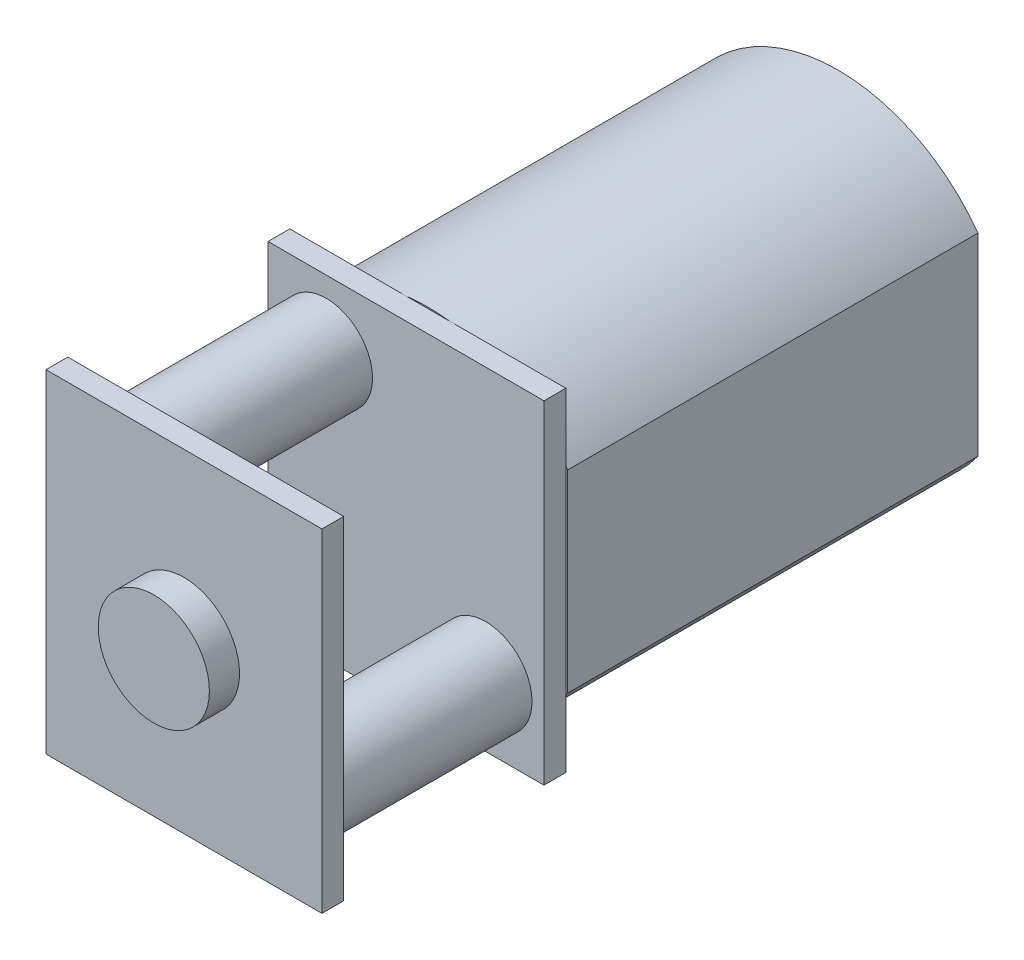
from build123d import *

# Parameters (mm, degrees)
BOSS_EXTRU_2_DEPTH = 14.69
ESQUISSE2_W        = 9.88
ESQUISSE2_H        = 11.92
BOSS_EXTRU_3_DEPTH = 0.78
ESQUISSE3_R        = 1.655
BOSS_EXTRU_4_DEPTH = 7.17
ESQUISSE4_W        = 9.88
ESQUISSE4_H        = 11.92
BOSS_EXTRU_5_DEPTH = 0.78
ESQUISSE5_R        = 1.99
BOSS_EXTRU_6_DEPTH = 1.08


with BuildPart() as part:
    # Esquisse1 → Boss.-Extru.2 (new body)
    with BuildSketch(Plane.XY):
        with BuildLine():
            Line((0, 0), (0, 6.92))
            ThreePointArc((0, 6.92), (5.01, 9.47), (10.02, 6.92))
            Line((10.02, 6.92), (10.02, 0))
            ThreePointArc((10.02, 0), (5.01, -2.55), (0, 0))
        make_face()
    extrude(amount=BOSS_EXTRU_2_DEPTH)

    # Esquisse2 → Boss.-Extru.3 (add)
    with BuildSketch(Plane.XY.offset(14.69)):
        with Locations((5.01, 3.46)):
            Rectangle(ESQUISSE2_W, ESQUISSE2_H)
    extrude(amount=BOSS_EXTRU_3_DEPTH)

    # Esquisse3 → Boss.-Extru.4 (add)
    with BuildSketch(Plane.XY.offset(15.47)):
        with Locations((7.865, -0.125)):
            Circle(ESQUISSE3_R)
        with Locations((2.155, 7.045)):
            Circle(ESQUISSE3_R)
    extrude(amount=BOSS_EXTRU_4_DEPTH)

    # Esquisse4 → Boss.-Extru.5 (add)
    with BuildSketch(Plane.XY.offset(22.64)):
        with Locations((5.01, 3.46)):
            Rectangle(ESQUISSE4_W, ESQUISSE4_H)
    extrude(amount=BOSS_EXTRU_5_DEPTH)

    # Esquisse5 → Boss.-Extru.6 (add)
    with BuildSketch(Plane.XY.offset(23.42)):
        with Locations((5.01, 3.46)):
            Circle(ESQUISSE5_R)
    extrude(amount=BOSS_EXTRU_6_DEPTH)


solid = part.part
